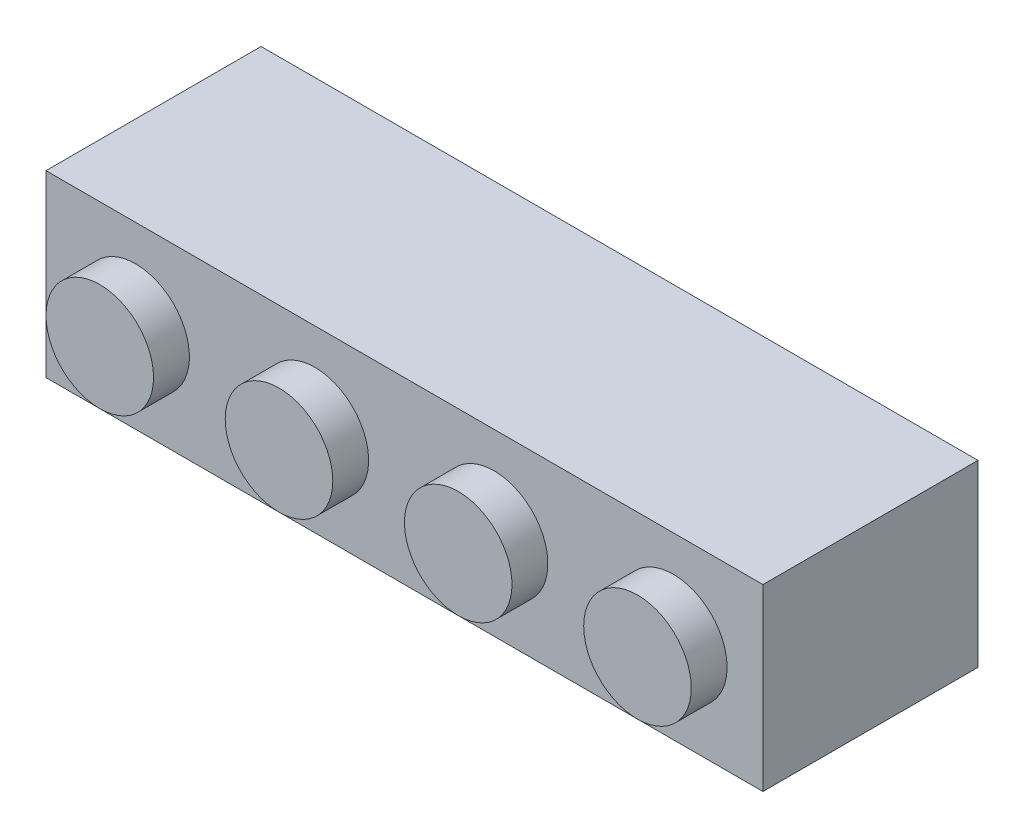
from build123d import *

# Parameters (mm, degrees)
SKETCH1_W           = 32
SKETCH1_H           = 8
BOSS_EXTRUDE1_DEPTH = 9.6
SKETCH2_R           = 2.4
BOSS_EXTRUDE2_DEPTH = 1.6
LPATTERN1_COUNT     = 4
LPATTERN1_PITCH     = 8
SHELL1_T            = -1.6
SKETCH3_R           = 1.6
BOSS_EXTRUDE3_DEPTH = 8
LPATTERN2_COUNT     = 3
LPATTERN2_PITCH     = 8


with BuildPart() as part:
    # Sketch1 → Boss-Extrude1 (new body)
    with BuildSketch(Plane.XY):
        with Locations((16, 4)):
            Rectangle(SKETCH1_W, SKETCH1_H)
    extrude(amount=BOSS_EXTRUDE1_DEPTH)

    # Sketch2 → Boss-Extrude2 (add)
    with BuildSketch(Plane.XY.offset(9.6)):
        with Locations((4, 4)):
            Circle(SKETCH2_R)
    boss_extrude2 = extrude(amount=BOSS_EXTRUDE2_DEPTH)

    # LPattern1: Boss-Extrude2 ×4
    with Locations(*[(i * LPATTERN1_PITCH, 0, 0) for i in range(1, LPATTERN1_COUNT)]):
        add(boss_extrude2)

    # Shell1
    shell1_openings = [part.faces().sort_by_distance(p)[0] for p in [
        (16, 4, 0),
    ]]
    offset(amount=SHELL1_T, openings=shell1_openings, kind=Kind.INTERSECTION)

    # Sketch3 → Boss-Extrude3 (add)
    with BuildSketch(Plane(origin=(0, 0, 8), x_dir=(-1, 0, 0), z_dir=(0, 0, -1))):
        with Locations((-8, 4)):
            Circle(SKETCH3_R)
    boss_extrude3 = extrude(amount=BOSS_EXTRUDE3_DEPTH)

    # LPattern2: Boss-Extrude3 ×3
    with Locations(*[(i * LPATTERN2_PITCH, 0, 0) for i in range(1, LPATTERN2_COUNT)]):
        add(boss_extrude3)


solid = part.part
